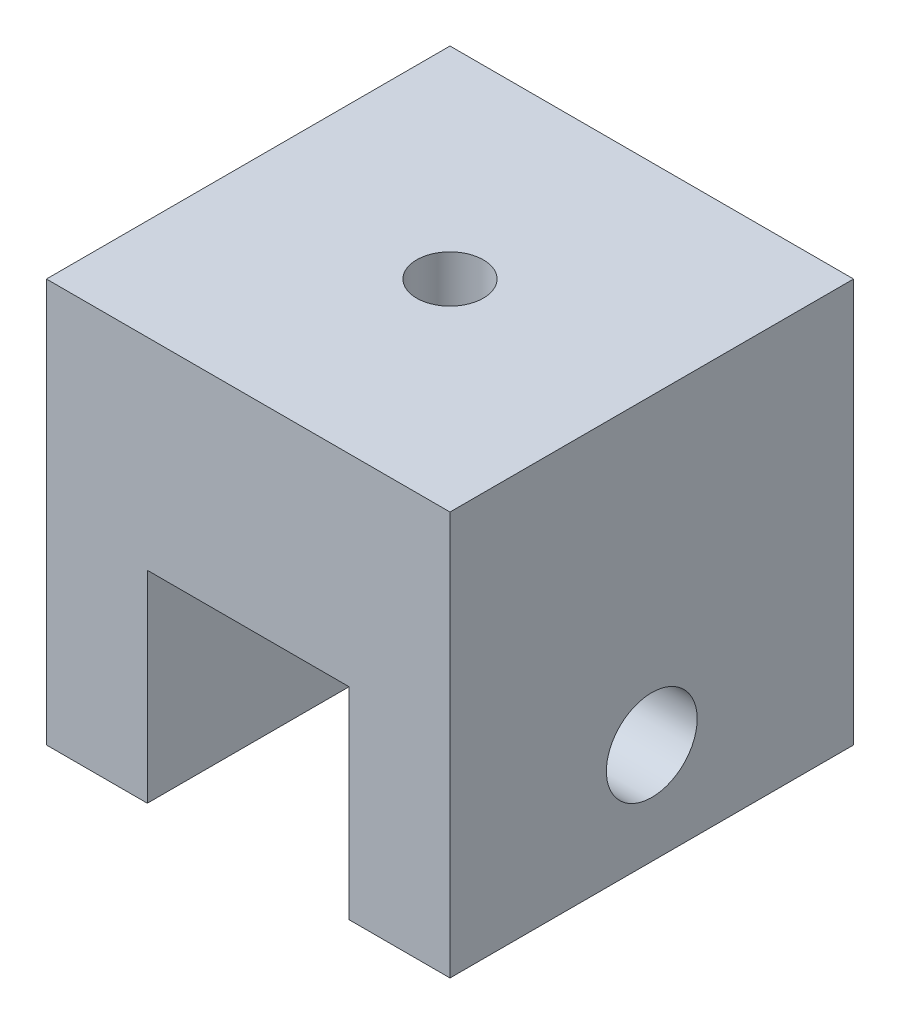
from build123d import *

# Parameters (mm, degrees)
SKETCH1_W           = 40
SKETCH1_H           = 40
BOSS_EXTRUDE1_DEPTH = 40
SKETCH2_R           = 3.3
CUT_EXTRUDE1_DEPTH  = 40
SKETCH3_W           = 20
SKETCH3_H           = 40
CUT_EXTRUDE2_DEPTH  = 40
SKETCH4_R           = 4.5
CUT_EXTRUDE3_DEPTH  = 40


with BuildPart() as part:
    # Sketch1 → Boss-Extrude1 (new body)
    with BuildSketch(Plane(origin=(0, 0, 0), x_dir=(1, 0, 0), z_dir=(0, 1, 0))):
        Rectangle(SKETCH1_W, SKETCH1_H)
    extrude(amount=BOSS_EXTRUDE1_DEPTH)

    # Sketch2 → Cut-Extrude1 (cut)
    with BuildSketch(Plane(origin=(0, 40, 0), x_dir=(1, 0, 0), z_dir=(0, 1, 0))):
        Circle(SKETCH2_R)
    extrude(amount=-CUT_EXTRUDE1_DEPTH, mode=Mode.SUBTRACT)

    # Sketch3 → Cut-Extrude2 (cut)
    with BuildSketch(Plane.XY.offset(20)):
        Rectangle(SKETCH3_W, SKETCH3_H)
    extrude(amount=-CUT_EXTRUDE2_DEPTH, mode=Mode.SUBTRACT)

    # Sketch4 → Cut-Extrude3 (cut)
    with BuildSketch(Plane(origin=(20, 0, 0), x_dir=(0, 0, -1), z_dir=(1, 0, 0))):
        with Locations((0, 10)):
            Circle(SKETCH4_R)
    extrude(amount=-CUT_EXTRUDE3_DEPTH, mode=Mode.SUBTRACT)


solid = part.part
